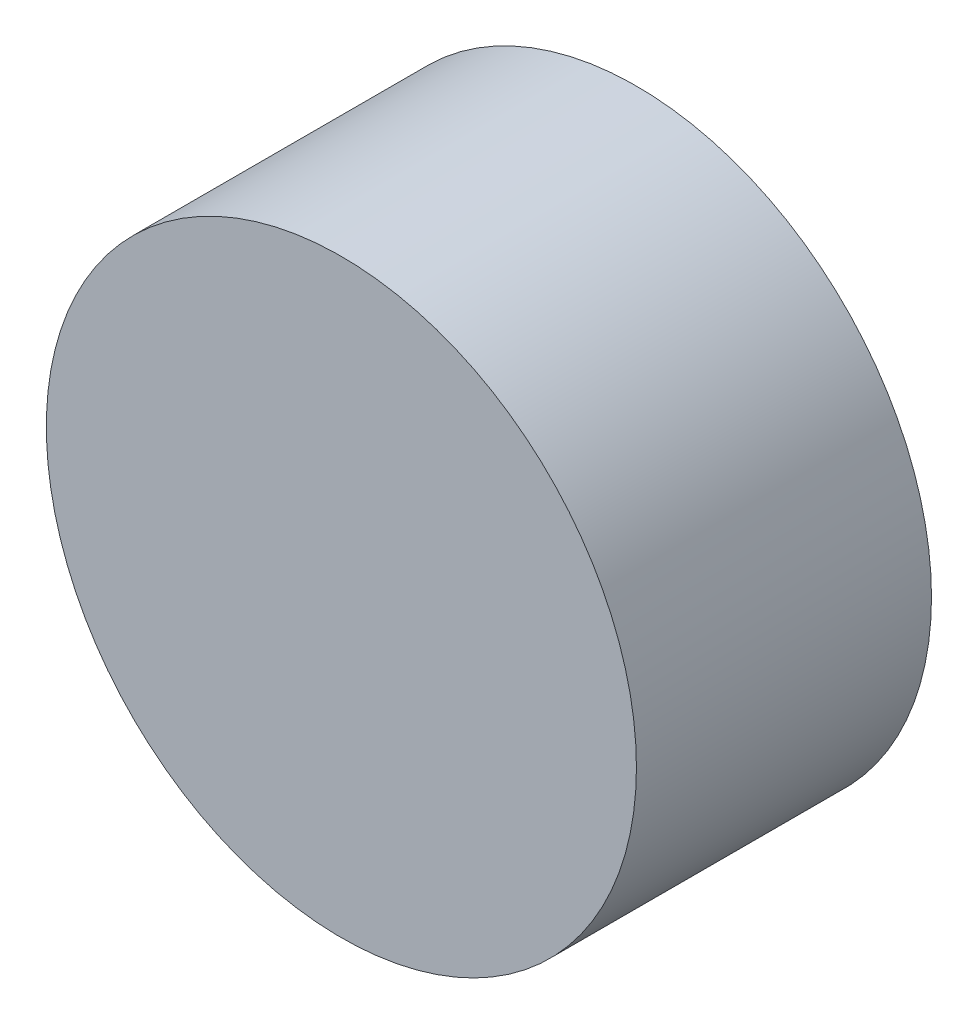
from build123d import *

# Parameters (mm, degrees)
SKETCH1_R           = 3.175
BOSS_EXTRUDE1_DEPTH = 3.175


with BuildPart() as part:
    # Sketch1 → Boss-Extrude1 (new body)
    with BuildSketch(Plane.XY):
        Circle(SKETCH1_R)
    extrude(amount=BOSS_EXTRUDE1_DEPTH)


solid = part.part
